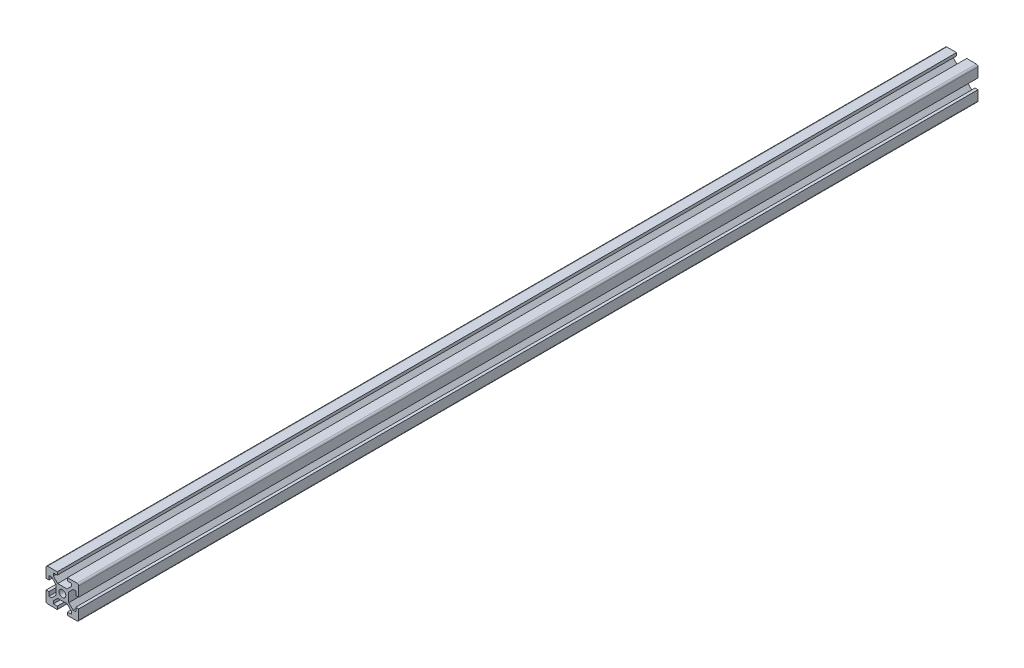
from build123d import *

# Parameters (mm, degrees)
BOSS_EXTRUDE1_DEPTH = 275
SKETCH2_R           = 2.1
CUT_EXTRUDE1_DEPTH  = 551
FILLET1_R           = 1


with BuildPart() as part:
    # Sketch1 → Boss-Extrude1 (new body, symmetric)
    with BuildSketch(Plane.XY):
        Polygon((-3.1, 10), (-3.1, 8.200660172), (-5.5, 8.200660172), (-5.5, 6.560660172), (-2.84, 3.900660172), (2.84, 3.900660172), (5.5, 6.560660172), (5.5, 8.200660172), (3.1, 8.200660172), (3.1, 10), (10, 10), (10, 3.1), (8.200660172, 3.1), (8.200660172, 5.5), (6.560660172, 5.5), (3.900660172, 2.84), (3.900660172, -2.84), (6.560660172, -5.5), (8.200660172, -5.5), (8.200660172, -3.1), (10, -3.1), (10, -10), (3.1, -10), (3.1, -8.200660172), (5.5, -8.200660172), (5.5, -6.560660172), (2.84, -3.900660172), (-2.84, -3.900660172), (-5.5, -6.560660172), (-5.5, -8.200660172), (-3.1, -8.200660172), (-3.1, -10), (-10, -10), (-10, -3.1), (-8.200660172, -3.1), (-8.200660172, -5.5), (-6.560660172, -5.5), (-3.900660172, -2.84), (-3.900660172, 2.84), (-6.560660172, 5.5), (-8.200660172, 5.5), (-8.200660172, 3.1), (-10, 3.1), (-10, 10), align=None)
    extrude(amount=BOSS_EXTRUDE1_DEPTH, both=True)

    # Sketch2 → Cut-Extrude1 (cut, through all)
    with BuildSketch(Plane.XY.offset(275)):
        Circle(SKETCH2_R)
    extrude(amount=-CUT_EXTRUDE1_DEPTH, mode=Mode.SUBTRACT)

    # Fillet1
    fillet1_edges = [part.edges().sort_by_distance(p)[0] for p in [
        (-10, -10, 0),
        (-10, 10, 0),
        (10, 10, 0),
        (10, -10, 0),
    ]]
    fillet(fillet1_edges, radius=FILLET1_R)


solid = part.part
